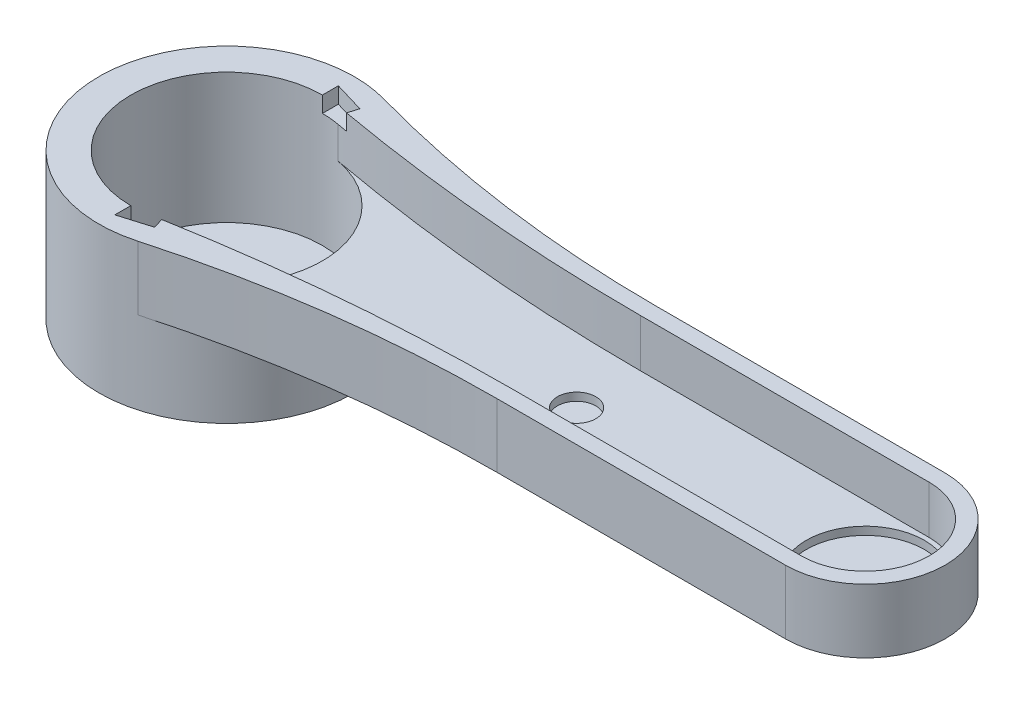
from build123d import *

# Parameters (mm, degrees)
BOSS_EXTRUDE1_DEPTH     = 15
SKETCH2_R               = 40
SKETCH2_R_2             = 30
BOSS_EXTRUDE2_DEPTH     = 25.8
SKETCH3_R               = 40
BOSS_EXTRUDE3_DEPTH     = 5
SKETCH4_R               = 6
SKETCH4_R_2             = 18.5
BOSS_EXTRUDE4_DEPTH     = 5
SKETCH6_R               = 6
SKETCH6_R_2             = 18.5
BOSS_EXTRUDE5_DEPTH     = 2.5
CUT_EXTRUDE1_DEPTH      = 5
SKETCH8_R               = 1.5
CUT_EXTRUDE2_DEPTH      = 1
CUT_EXTRUDE2_DEPTH_BACK = 46.8


with BuildPart() as part:
    # Sketch1 → Boss-Extrude1 (new body)
    with BuildSketch(Plane(origin=(0, 0, 0), x_dir=(1, 0, 0), z_dir=(0, 1, 0))):
        with BuildLine():
            ThreePointArc((200, -25), (225, 0), (200, 25))
            Line((200, 25), (109.6, 25))
            ThreePointArc((109.6, 25), (59.713041879, 28.397959328), (10.747591761, 38.529070471))
            ThreePointArc((10.747591761, 38.529070471), (-40, 0), (10.747591761, -38.529070471))
            ThreePointArc((10.747591761, -38.529070471), (59.713041879, -28.397959328), (109.6, -25))
            Line((109.6, -25), (200, -25))
        make_face()
        with BuildLine():
            Line((109.6, 20), (200, 20))
            ThreePointArc((200, 20), (220, 0), (200, -20))
            Line((200, -20), (109.6, -20))
            ThreePointArc((109.6, -20), (57.298273937, -22.381082353), (5.429254567, -29.504630058))
            ThreePointArc((5.429254567, -29.504630058), (-30, 0), (5.429254567, 29.504630058))
            ThreePointArc((5.429254567, 29.504630058), (57.298273937, 22.381082353), (109.6, 20))
        make_face(mode=Mode.SUBTRACT)
    extrude(amount=BOSS_EXTRUDE1_DEPTH)

    # Sketch2 → Boss-Extrude2 (add)
    with BuildSketch(Plane.XZ):
        Circle(SKETCH2_R)
        Circle(SKETCH2_R_2, mode=Mode.SUBTRACT)
    extrude(amount=BOSS_EXTRUDE2_DEPTH)

    # Sketch3 → Boss-Extrude3 (add)
    with BuildSketch(Plane.XZ.offset(25.8)):
        Circle(SKETCH3_R)
    extrude(amount=BOSS_EXTRUDE3_DEPTH)

    # Sketch4 → Boss-Extrude4 (add)
    with BuildSketch(Plane.XZ):
        with BuildLine():
            ThreePointArc((185, -20), (175, 0), (185, 20))
            Line((185, 20), (109.6, 20))
            ThreePointArc((109.6, 20), (70.154992453, 21.353125364), (30.895437645, 25.406139666))
            ThreePointArc((30.895437645, 25.406139666), (37.655129171, 13.494118982), (40, 0))
            ThreePointArc((40, 0), (37.655129171, -13.494118982), (30.895437645, -25.406139666))
            ThreePointArc((30.895437645, -25.406139666), (70.154992453, -21.353125364), (109.6, -20))
            Line((109.6, -20), (185, -20))
        make_face()
        with Locations((109.6, 0)):
            Circle(SKETCH4_R, mode=Mode.SUBTRACT)
        with BuildLine():
            Line((200, 20), (185, 20))
            ThreePointArc((185, 20), (175, 0), (185, -20))
            Line((185, -20), (200, -20))
            ThreePointArc((200, -20), (220, 0), (200, 20))
        make_face()
        with Locations((200, 0)):
            Circle(SKETCH4_R_2, mode=Mode.SUBTRACT)
        with BuildLine():
            ThreePointArc((225, 0), (217.67766953, 17.67766953), (200, 25))
            ThreePointArc((200, 25), (192.09430585, 23.717082451), (185, 20))
            Line((185, 20), (200, 20))
            ThreePointArc((200, 20), (220, 0), (200, -20))
            Line((200, -20), (185, -20))
            ThreePointArc((185, -20), (192.09430585, -23.717082451), (200, -25))
            ThreePointArc((200, -25), (217.67766953, -17.67766953), (225, 0))
        make_face()
        with BuildLine():
            ThreePointArc((185, 20), (192.09430585, 23.717082451), (200, 25))
            Line((200, 25), (109.6, 25))
            ThreePointArc((109.6, 25), (59.713041879, 28.397959328), (10.747591761, 38.529070471))
            ThreePointArc((10.747591761, 38.529070471), (21.830902473, 33.51733428), (30.895437645, 25.406139666))
            ThreePointArc((30.895437645, 25.406139666), (70.154992453, 21.353125364), (109.6, 20))
            Line((109.6, 20), (185, 20))
        make_face()
        with BuildLine():
            Line((109.6, -25), (200, -25))
            ThreePointArc((200, -25), (192.09430585, -23.717082451), (185, -20))
            Line((185, -20), (109.6, -20))
            ThreePointArc((109.6, -20), (70.154992453, -21.353125364), (30.895437645, -25.406139666))
            ThreePointArc((30.895437645, -25.406139666), (21.830902473, -33.51733428), (10.747591761, -38.529070471))
            ThreePointArc((10.747591761, -38.529070471), (59.713041879, -28.397959328), (109.6, -25))
        make_face()
    extrude(amount=BOSS_EXTRUDE4_DEPTH)

    # Sketch6 → Boss-Extrude5 (add)
    with BuildSketch(Plane.XZ.offset(5)):
        with Locations((109.6, 0)):
            Circle(SKETCH6_R)
        with Locations((200, 0)):
            Circle(SKETCH6_R_2)
    extrude(amount=-BOSS_EXTRUDE5_DEPTH)

    # Sketch7 → Cut-Extrude1 (cut)
    with BuildSketch(Plane(origin=(0, 15, 0), x_dir=(1, 0, 0), z_dir=(0, 1, 0))):
        with BuildLine():
            ThreePointArc((5.429254567, -29.504630058), (2.725903361, -29.875900838), (0, -30))
            Line((0, -30), (0, -35))
            Line((0, -35), (9.583148475, -32.142857143))
            Line((9.583148475, -32.142857143), (8.624081591, -28.926049021))
            ThreePointArc((8.624081591, -28.926049021), (7.026260133, -29.213086928), (5.429254567, -29.504630058))
        make_face()
        with BuildLine():
            Line((0, 35), (0, 30))
            ThreePointArc((0, 30), (2.725903361, 29.875900838), (5.429254567, 29.504630058))
            ThreePointArc((5.429254567, 29.504630058), (7.026260133, 29.213086928), (8.624081591, 28.926049021))
            Line((8.624081591, 28.926049021), (9.583148475, 32.142857143))
            Line((9.583148475, 32.142857143), (0, 35))
        make_face()
    extrude(amount=-CUT_EXTRUDE1_DEPTH, mode=Mode.SUBTRACT)

    # Sketch8 → Cut-Extrude2 (cut, two sides)
    with BuildSketch(Plane.XZ.offset(30.8)) as cut_extrude2_sk:
        with Locations((0, 15)):
            Circle(SKETCH8_R)
        with Locations((15, 0)):
            Circle(SKETCH8_R)
        with Locations((0, -15)):
            Circle(SKETCH8_R)
        with Locations((-15, 0)):
            Circle(SKETCH8_R)
    extrude(amount=CUT_EXTRUDE2_DEPTH, mode=Mode.SUBTRACT)
    extrude(cut_extrude2_sk.sketch, amount=-CUT_EXTRUDE2_DEPTH_BACK, mode=Mode.SUBTRACT)


solid = part.part
